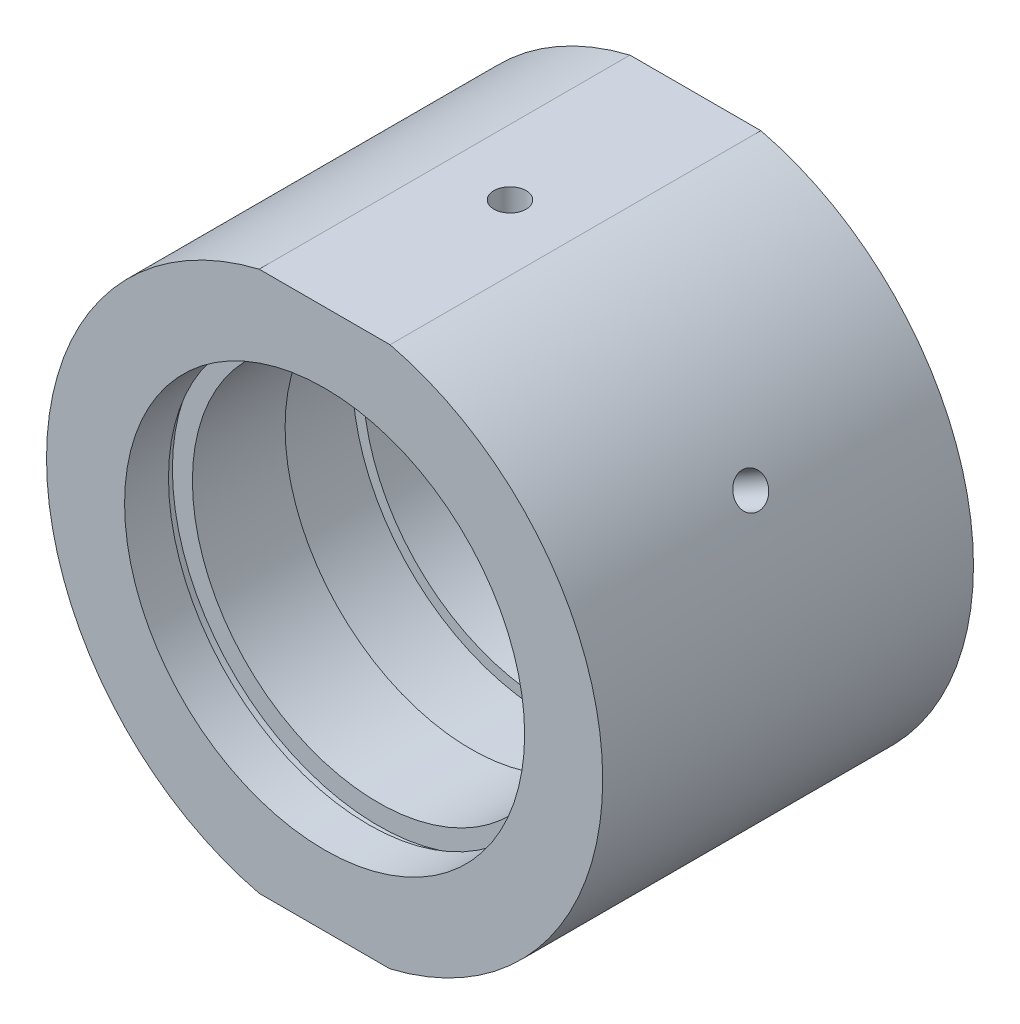
from build123d import *

# Parameters (mm, degrees)
SKETCH_2_W                       = 64.02174429
SKETCH_2_H                       = 9.248919907
CUT_EXTRUDE_1_DEPTH              = 49
HOLE_WIZARD_M4_2_D               = 3.3
HOLE_WIZARD_M4_2_DEPTH           = 5.5
HOLE_WIZARD_M4_2_TIP             = 0.991420021
HOLE_WIZARD_M6_2_D               = 5
HOLE_WIZARD_M6_2_DEPTH           = 5.5
HOLE_WIZARD_M6_2_TIP             = 1.502151548
HOLE_WIZARD_M4_3_D               = 3.3
HOLE_WIZARD_M4_3_DEPTH           = 10.1
HOLE_WIZARD_M4_3_TIP             = 0.991420021
HOLE_WIZARD_M4_3_ON_FACE_2_D     = 3.3
HOLE_WIZARD_M4_3_ON_FACE_2_DEPTH = 10.1
HOLE_WIZARD_M4_3_ON_FACE_2_TIP   = 0.991420021


with BuildPart() as part:
    # 草图1 → 旋转1 (revolve)
    with BuildSketch(Plane(origin=(0, 0, 0), x_dir=(1, 0, 0), z_dir=(0, 1, 0)), mode=Mode.PRIVATE) as revolve_1_sk:
        Polygon((28.5, 19), (28.5, -19), (20.5, -19), (20.5, -14.5), (21.1, -14.5), (21.1, -13.5), (19.05, -13.5), (19.05, -4), (20.15, -4), (20.15, 4), (19.05, 4), (19.05, 13.5), (21.1, 13.5), (21.1, 14.5), (20.5, 14.5), (20.5, 19), align=None)
    revolve(revolve_1_sk.sketch.rotate(Axis((0, 0, -31.9390681), (0, 0, 1)), 180), axis=Axis((0, 0, -31.9390681), (0, 0, 1)))  # turned: the seam where the file's is

    # 草图2 → 切除-拉伸1 (cut)
    with BuildSketch(Plane.XY.offset(19)):
        with Locations((-1.141100508, 32.324459954)):
            Rectangle(SKETCH_2_W, SKETCH_2_H)
        with Locations((-1.141100508, -32.324459954)):
            Rectangle(SKETCH_2_W, SKETCH_2_H)
    extrude(amount=-CUT_EXTRUDE_1_DEPTH, mode=Mode.SUBTRACT)

    # M4 螺纹孔2
    with Locations(Plane(origin=(0, 27.7, 0), x_dir=(1, 0, 0), z_dir=(0, 1, 0))):
        with Locations((0, 0)):
            Hole(HOLE_WIZARD_M4_2_D / 2, depth=HOLE_WIZARD_M4_2_DEPTH)
            with Locations((0, 0, -(HOLE_WIZARD_M4_2_DEPTH + HOLE_WIZARD_M4_2_TIP / 2))):  # 118° drill point
                Cone(0, HOLE_WIZARD_M4_2_D / 2, HOLE_WIZARD_M4_2_TIP, mode=Mode.SUBTRACT)

    # M6 螺纹孔2
    with Locations(Plane(origin=(0, -27.7, 0), x_dir=(-1, 0, 0), z_dir=(0, -1, 0))):
        with Locations((0, 0)):
            Hole(HOLE_WIZARD_M6_2_D / 2, depth=HOLE_WIZARD_M6_2_DEPTH)
            with Locations((0, 0, -(HOLE_WIZARD_M6_2_DEPTH + HOLE_WIZARD_M6_2_TIP / 2))):  # 118° drill point
                Cone(0, HOLE_WIZARD_M6_2_D / 2, HOLE_WIZARD_M6_2_TIP, mode=Mode.SUBTRACT)

    # M4 螺纹孔3
    with Locations(Plane(origin=(24.681724008, 14.25, 0), x_dir=(-0.5, 0.866025404, 0), z_dir=(0.866025404, 0.5, 0))):
        with Locations((0, 0)):
            Hole(HOLE_WIZARD_M4_3_D / 2, depth=HOLE_WIZARD_M4_3_DEPTH)
            with Locations((0, 0, -(HOLE_WIZARD_M4_3_DEPTH + HOLE_WIZARD_M4_3_TIP / 2))):  # 118° drill point
                Cone(0, HOLE_WIZARD_M4_3_D / 2, HOLE_WIZARD_M4_3_TIP, mode=Mode.SUBTRACT)

    # M4 螺纹孔3 on face 2
    with Locations(Plane(origin=(-24.681724008, 14.25, 0), x_dir=(-0.500000175, -0.866025303, 0), z_dir=(-0.866025303, 0.500000175, 0))):
        with Locations((0, 0)):
            Hole(HOLE_WIZARD_M4_3_ON_FACE_2_D / 2, depth=HOLE_WIZARD_M4_3_ON_FACE_2_DEPTH)
            with Locations((0, 0, -(HOLE_WIZARD_M4_3_ON_FACE_2_DEPTH + HOLE_WIZARD_M4_3_ON_FACE_2_TIP / 2))):  # 118° drill point
                Cone(0, HOLE_WIZARD_M4_3_ON_FACE_2_D / 2, HOLE_WIZARD_M4_3_ON_FACE_2_TIP, mode=Mode.SUBTRACT)


solid = part.part
